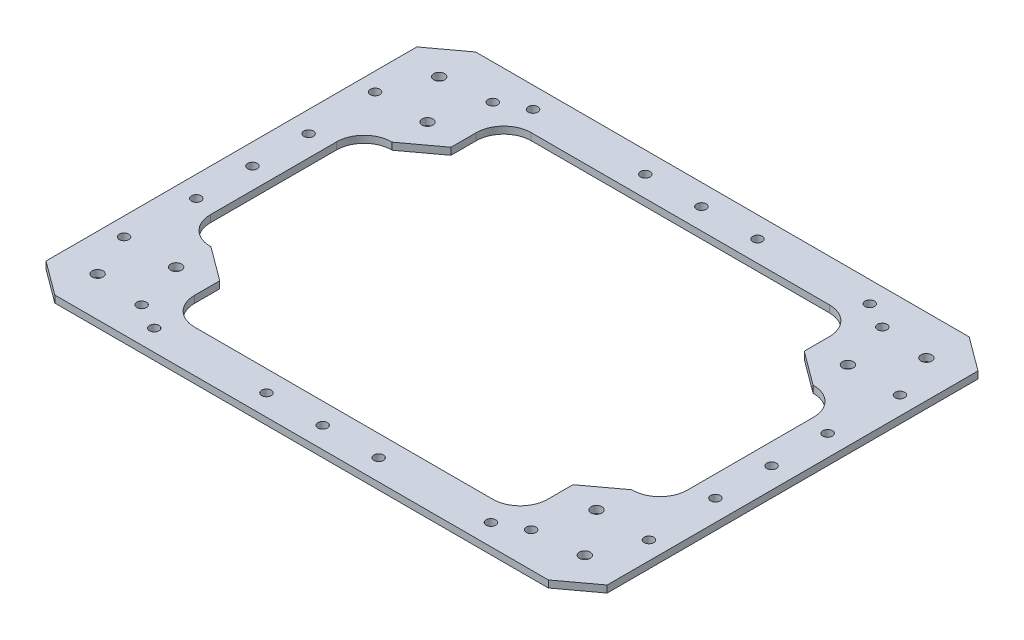
from build123d import *

# Parameters (mm, degrees)
BOSS_EXTRUDE1_DEPTH = 3.175
SKETCH2_R           = 2.4638
SKETCH2_R_2         = 2.159
CUT_EXTRUDE1_DEPTH  = 4.175
SKETCH3_R           = 2.159
CUT_EXTRUDE2_DEPTH  = 4.175


with BuildPart() as part:
    # Sketch1 → Boss-Extrude1 (new body)
    with BuildSketch(Plane(origin=(0, 0, 0), x_dir=(1, 0, 0), z_dir=(0, 1, 0))):
        Polygon((-111.686526805, 95.25), (-127, 83.918625912), (-127, -83.918625912), (-111.686526805, -95.25), (111.686526805, -95.25), (127, -83.918625912), (127, 83.918625912), (111.686526805, 95.25), align=None)
        with BuildLine():
            Line((-107.95, -28.564963508), (-107.95, 28.564963508))
            ThreePointArc((-107.95, 28.564963508), (-104.304650999, 37.365614506), (-95.504, 41.010963508))
            Line((-95.504, 41.010963508), (-95.25, 41.010963508))
            Line((-95.25, 41.010963508), (-79.936526805, 52.342337595))
            Line((-79.936526805, 52.342337595), (-79.936526805, 63.754))
            ThreePointArc((-79.936526805, 63.754), (-76.291177804, 72.554650999), (-67.490526805, 76.2))
            Line((-67.490526805, 76.2), (67.490526805, 76.2))
            ThreePointArc((67.490526805, 76.2), (76.291177804, 72.554650999), (79.936526805, 63.754))
            Line((79.936526805, 63.754), (79.936526805, 52.342337595))
            Line((79.936526805, 52.342337595), (95.25, 41.010963508))
            Line((95.25, 41.010963508), (95.504, 41.010963508))
            ThreePointArc((95.504, 41.010963508), (104.304650999, 37.365614506), (107.95, 28.564963508))
            Line((107.95, 28.564963508), (107.95, -28.564963508))
            ThreePointArc((107.95, -28.564963508), (104.304650999, -37.365614506), (95.504, -41.010963508))
            Line((95.504, -41.010963508), (95.25, -41.010963508))
            Line((95.25, -41.010963508), (79.936526805, -52.342337595))
            Line((79.936526805, -52.342337595), (79.936526805, -63.754))
            ThreePointArc((79.936526805, -63.754), (76.291177804, -72.554650999), (67.490526805, -76.2))
            Line((67.490526805, -76.2), (-67.490526805, -76.2))
            ThreePointArc((-67.490526805, -76.2), (-76.291177804, -72.554650999), (-79.936526805, -63.754))
            Line((-79.936526805, -63.754), (-79.936526805, -52.342337595))
            Line((-79.936526805, -52.342337595), (-95.25, -41.010963508))
            Line((-95.25, -41.010963508), (-95.504, -41.010963508))
            ThreePointArc((-95.504, -41.010963508), (-104.304650999, -37.365614506), (-107.95, -28.564963508))
        make_face(mode=Mode.SUBTRACT)
    extrude(amount=BOSS_EXTRUDE1_DEPTH)

    # Sketch2 → Cut-Extrude1 (cut, through all)
    with BuildSketch(Plane(origin=(0, 3.175, 0), x_dir=(1, 0, 0), z_dir=(0, 1, 0))):
        with Locations((-95.147512794, 56.885632681)):
            Circle(SKETCH2_R)
        with Locations((-110.256011578, 77.303596941)):
            Circle(SKETCH2_R)
        with Locations((110.256011578, 77.303596941)):
            Circle(SKETCH2_R)
        with Locations((95.147512794, 56.885632681)):
            Circle(SKETCH2_R)
        with Locations((110.256011578, -77.303596941)):
            Circle(SKETCH2_R)
        with Locations((95.147512794, -56.885632681)):
            Circle(SKETCH2_R)
        with Locations((-110.256011578, -77.303596941)):
            Circle(SKETCH2_R)
        with Locations((-95.147512794, -56.885632681)):
            Circle(SKETCH2_R)
        with Locations((-88.154790208, 79.461855841)):
            Circle(SKETCH2_R_2)
        with Locations((-118.781736597, 56.799107666)):
            Circle(SKETCH2_R_2)
        with Locations((118.781736597, 56.799107666)):
            Circle(SKETCH2_R_2)
        with Locations((88.154790208, 79.461855841)):
            Circle(SKETCH2_R_2)
        with Locations((118.781736597, -56.799107666)):
            Circle(SKETCH2_R_2)
        with Locations((88.154790208, -79.461855841)):
            Circle(SKETCH2_R_2)
        with Locations((-88.154790208, -79.461855841)):
            Circle(SKETCH2_R_2)
        with Locations((-118.781736597, -56.799107666)):
            Circle(SKETCH2_R_2)
    extrude(amount=-CUT_EXTRUDE1_DEPTH, mode=Mode.SUBTRACT)

    # Sketch3 → Cut-Extrude2 (cut, through all)
    with BuildSketch(Plane(origin=(0, 3.175, 0), x_dir=(1, 0, 0), z_dir=(0, 1, 0))):
        with Locations((-76.2, 85.725)):
            Circle(SKETCH3_R)
        with Locations((-25.4, 85.725)):
            Circle(SKETCH3_R)
        with Locations((25.4, 85.725)):
            Circle(SKETCH3_R)
        with Locations((76.2, 85.725)):
            Circle(SKETCH3_R)
        with Locations((76.2, -85.725)):
            Circle(SKETCH3_R)
        with Locations((25.4, -85.725)):
            Circle(SKETCH3_R)
        with Locations((-25.4, -85.725)):
            Circle(SKETCH3_R)
        with Locations((-76.2, -85.725)):
            Circle(SKETCH3_R)
        with Locations((-117.475, -25.4)):
            Circle(SKETCH3_R)
        with Locations((-117.475, 25.4)):
            Circle(SKETCH3_R)
        with Locations((117.475, 25.4)):
            Circle(SKETCH3_R)
        with Locations((117.475, -25.4)):
            Circle(SKETCH3_R)
        with Locations((0, 85.725)):
            Circle(SKETCH3_R)
        with Locations((0, -85.725)):
            Circle(SKETCH3_R)
        with Locations((-117.475, 0)):
            Circle(SKETCH3_R)
        with Locations((117.475, 0)):
            Circle(SKETCH3_R)
    extrude(amount=-CUT_EXTRUDE2_DEPTH, mode=Mode.SUBTRACT)


solid = part.part
